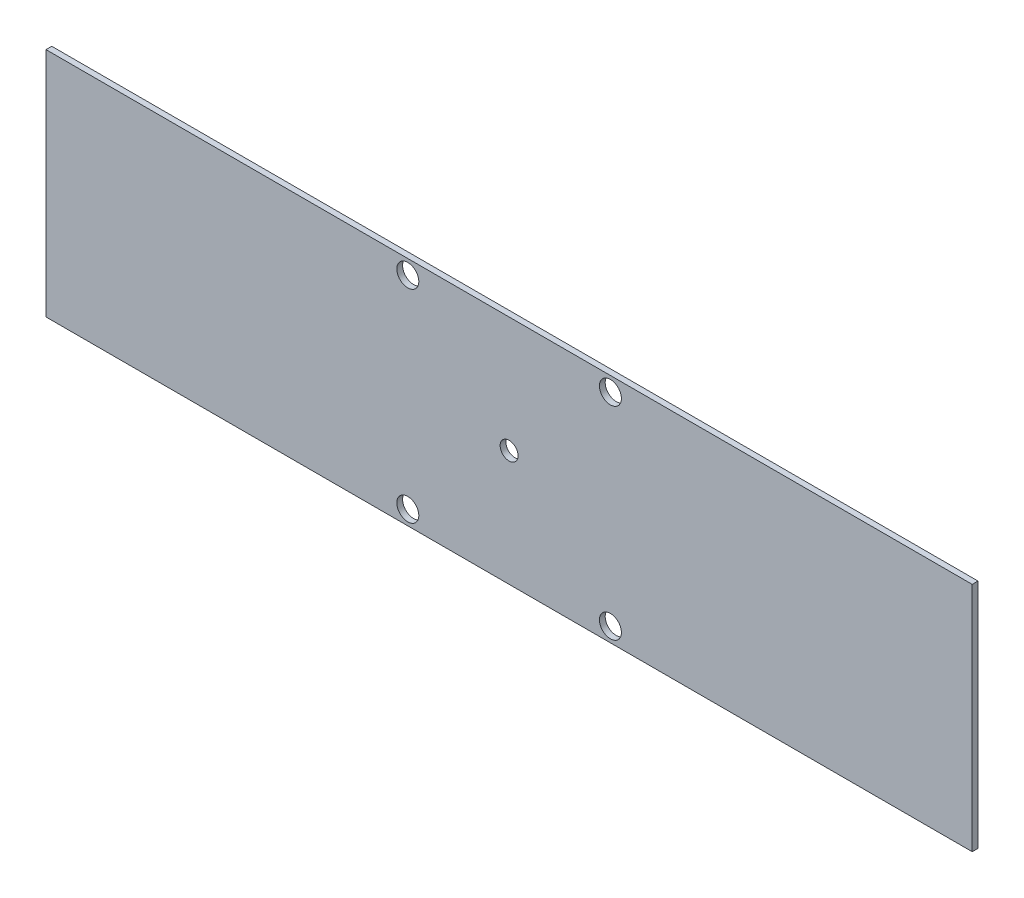
from build123d import *

# Parameters (mm, degrees)
SKETCH2_W           = 406.4
SKETCH2_H           = 101.6
BOSS_EXTRUDE2_DEPTH = 2.54
SKETCH3_R           = 4.826
CUT_EXTRUDE1_DEPTH  = 2.54
SKETCH4_R           = 3.937
CUT_EXTRUDE2_DEPTH  = 2.54
SKETCH5_W           = 12.7
SKETCH5_H           = 76.2
BOSS_EXTRUDE4_DEPTH = 12.7


with BuildPart() as part:
    # Sketch2 → Boss-Extrude2 (new body)
    with BuildSketch(Plane.XY):
        Rectangle(SKETCH2_W, SKETCH2_H)
    extrude(amount=-BOSS_EXTRUDE2_DEPTH)

    # Sketch3 → Cut-Extrude1 (cut)
    with BuildSketch(Plane.XY):
        with Locations((-44.45, 44.45)):
            Circle(SKETCH3_R)
        with Locations((44.45, 44.45)):
            Circle(SKETCH3_R)
        with Locations((44.45, -44.45)):
            Circle(SKETCH3_R)
        with Locations((-44.45, -44.45)):
            Circle(SKETCH3_R)
    extrude(amount=-CUT_EXTRUDE1_DEPTH, mode=Mode.SUBTRACT)

    # Sketch4 → Cut-Extrude2 (cut)
    with BuildSketch(Plane.XY):
        Circle(SKETCH4_R)
    extrude(amount=-CUT_EXTRUDE2_DEPTH, mode=Mode.SUBTRACT)

    # Sketch5 → Boss-Extrude4 (add)
    with BuildSketch(Plane.XY):
        with Locations((-184.15, 0)):
            Rectangle(SKETCH5_W, SKETCH5_H)
    boss_extrude4 = extrude(amount=-BOSS_EXTRUDE4_DEPTH)

    # Mirror2: Boss-Extrude4 across plane
    add(boss_extrude4.mirror(Plane(origin=(0, 0, 0), x_dir=(0, 0, 1), z_dir=(1, 0, 0))))


solid = part.part
